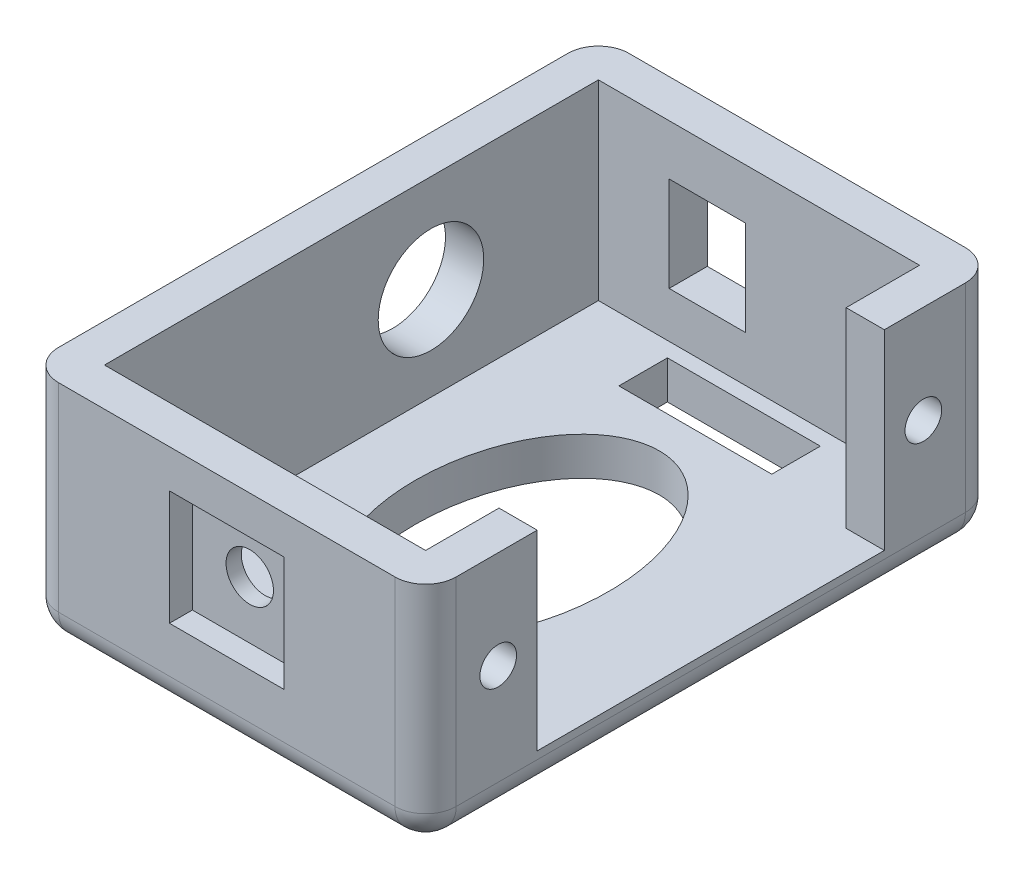
from build123d import *

# Parameters (mm, degrees)
BOSS_EXTRUDE1_DEPTH = 15
SKETCH2_W           = 32.3
SKETCH2_H           = 2.5
BOSS_EXTRUDE2_DEPTH = 23.5
SKETCH3_W           = 5
SKETCH3_H           = 6.2
CUT_EXTRUDE1_DEPTH  = 12.5
CUT_EXTRUDE2_REACH  = 28
SKETCH4_R           = 3.45
SKETCH5_R           = 1.2
CUT_EXTRUDE3_DEPTH  = 2.5
CUT_EXTRUDE4_REACH  = 39.3
SKETCH6_R           = 1.55
FILLET2_R           = 2
SKETCH7_W           = 7.5
SKETCH7_H           = 7.5
SKETCH7_R           = 1.55
CUT_EXTRUDE5_DEPTH  = 1.5
CUT_EXTRUDE6_REACH  = 4.5
SKETCH8_RX          = 9.634046057
SKETCH8_RY          = 6.312870092
SKETCH8_W           = 10
SKETCH8_H           = 3.175


with BuildPart() as part:
    # Sketch1 → Boss-Extrude1 (new body)
    with BuildSketch(Plane(origin=(0, 0, 0), x_dir=(1, 0, 0), z_dir=(0, 1, 0))):
        Polygon((0, 29.994099724), (-26, 29.994099724), (-26, -7.305900276), (0, -7.305900276), (0, -0.005900276), (-2.5, -0.005900276), (-2.5, -4.805900276), (-23.5, -4.805900276), (-23.5, 27.494099724), (-2.5, 27.494099724), (-2.5, 22.694099724), (0, 22.694099724), align=None)
    extrude(amount=BOSS_EXTRUDE1_DEPTH)

    # Sketch2 → Boss-Extrude2 (add, through all)
    with BuildSketch(Plane(origin=(-23.5, 0, 0), x_dir=(0, 0, -1), z_dir=(1, 0, 0))):
        with Locations((11.344099724, 1.25)):
            Rectangle(SKETCH2_W, SKETCH2_H)
    extrude(amount=BOSS_EXTRUDE2_DEPTH)

    # Sketch3 → Cut-Extrude1 (cut)
    with BuildSketch(Plane(origin=(0, 0, -29.994099724), x_dir=(-1, 0, 0), z_dir=(0, 0, -1))):
        with Locations((16.375, 8.6)):
            Rectangle(SKETCH3_W, SKETCH3_H)
    extrude(amount=-CUT_EXTRUDE1_DEPTH, mode=Mode.SUBTRACT)

    # Sketch4 → Cut-Extrude2 (cut, up to next)
    with BuildSketch(Plane.ZY.offset(26), mode=Mode.PRIVATE) as cut_extrude2_sk1:
        with Locations((-16.544099724, 8.6)):
            Circle(SKETCH4_R)
    cut_extrude2_tool1 = extrude(cut_extrude2_sk1.sketch, amount=-CUT_EXTRUDE2_REACH, mode=Mode.PRIVATE) & part.part
    add(cut_extrude2_tool1.solids().sort_by_distance((-26, 8.6, -16.5441))[0], mode=Mode.SUBTRACT)

    # Sketch5 → Cut-Extrude3 (cut)
    with BuildSketch(Plane(origin=(0, 0, 0), x_dir=(0, 0, -1), z_dir=(1, 0, 0))):
        with Locations((-2.555900276, 8.6)):
            Circle(SKETCH5_R)
    cut_extrude3 = extrude(amount=-CUT_EXTRUDE3_DEPTH, mode=Mode.SUBTRACT)

    # Mirror1: Cut-Extrude3 across plane
    add(cut_extrude3.mirror(Plane.XY.offset(-11.344099724)), mode=Mode.SUBTRACT)

    # Sketch6 → Cut-Extrude4 (cut, up to next)
    with BuildSketch(Plane.XY.offset(7.305900276), mode=Mode.PRIVATE) as cut_extrude4_sk1:
        with Locations((-13, 8.75)):
            Circle(SKETCH6_R)
    cut_extrude4_tool1 = extrude(cut_extrude4_sk1.sketch, amount=-CUT_EXTRUDE4_REACH, mode=Mode.PRIVATE) & part.part
    add(cut_extrude4_tool1.solids().sort_by_distance((-13, 8.75, 7.3059))[0], mode=Mode.SUBTRACT)

    # Fillet2
    fillet2_edges = [part.edges().sort_by_distance(p)[0] for p in [
        (0, 0, -11.344099724),
        (-13, 0, 7.305900276),
        (-26, 0, -11.344099724),
        (-13, 0, -29.994099724),
        (0, 7.5, 7.305900276),
        (-26, 7.5, 7.305900276),
        (-26, 7.5, -29.994099724),
        (0, 7.5, -29.994099724),
    ]]
    fillet(fillet2_edges, radius=FILLET2_R)

    # Sketch7 → Cut-Extrude5 (cut)
    with BuildSketch(Plane.XY.offset(7.305900276)):
        with Locations((-13, 8.75)):
            Rectangle(SKETCH7_W, SKETCH7_H)
        with Locations((-13, 8.75)):
            Circle(SKETCH7_R, mode=Mode.SUBTRACT)
    extrude(amount=-CUT_EXTRUDE5_DEPTH, mode=Mode.SUBTRACT)

    # Sketch8 → Cut-Extrude6 (cut, up to next)
    with BuildSketch(Plane(origin=(0, 2.5, 0), x_dir=(1, 0, 0), z_dir=(0, 1, 0)), mode=Mode.PRIVATE) as cut_extrude6_sk1:
        with Locations(Location((-13, 11.344099724), (0, 0, 90))):
            Ellipse(SKETCH8_RX, SKETCH8_RY)
    cut_extrude6_tool1 = extrude(cut_extrude6_sk1.sketch, amount=-CUT_EXTRUDE6_REACH, mode=Mode.PRIVATE) & part.part
    add(cut_extrude6_tool1.solids().sort_by_distance((-13, 2.5, -11.3441))[0], mode=Mode.SUBTRACT)
    # Sketch8 → Cut-Extrude6 (cut, up to next)
    with BuildSketch(Plane(origin=(0, 2.5, 0), x_dir=(1, 0, 0), z_dir=(0, 1, 0)), mode=Mode.PRIVATE) as cut_extrude6_sk2:
        with Locations((-13, -2.231384095)):
            Rectangle(SKETCH8_W, SKETCH8_H)
    cut_extrude6_tool2 = extrude(cut_extrude6_sk2.sketch, amount=-CUT_EXTRUDE6_REACH, mode=Mode.PRIVATE) & part.part
    add(cut_extrude6_tool2.solids().sort_by_distance((-13, 2.5, 2.231384))[0], mode=Mode.SUBTRACT)
    # Sketch8 → Cut-Extrude6 (cut, up to next)
    with BuildSketch(Plane(origin=(0, 2.5, 0), x_dir=(1, 0, 0), z_dir=(0, 1, 0)), mode=Mode.PRIVATE) as cut_extrude6_sk3:
        with Locations((-13, 24.919583542)):
            Rectangle(SKETCH8_W, SKETCH8_H)
    cut_extrude6_tool3 = extrude(cut_extrude6_sk3.sketch, amount=-CUT_EXTRUDE6_REACH, mode=Mode.PRIVATE) & part.part
    add(cut_extrude6_tool3.solids().sort_by_distance((-13, 2.5, -24.919584))[0], mode=Mode.SUBTRACT)


solid = part.part
